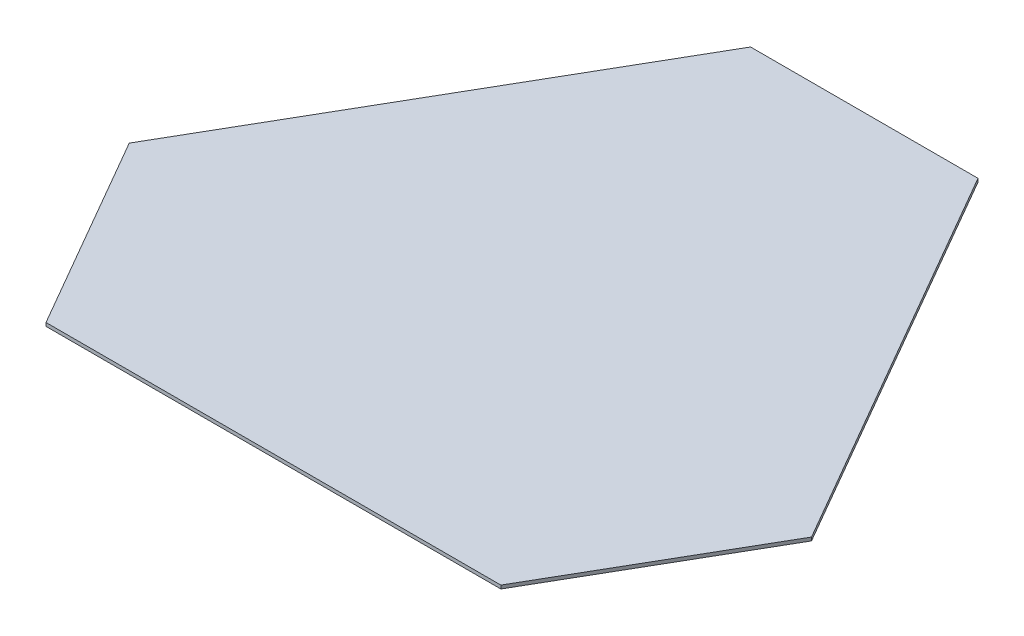
from build123d import *

# Parameters (mm, degrees)
BOSS_EXTRUDE1_DEPTH = 3


with BuildPart() as part:
    # Sketch2 → Boss-Extrude1 (new body)
    with BuildSketch(Plane(origin=(0, 0, 0), x_dir=(1, 0, 0), z_dir=(0, 1, 0))):
        Polygon((100, 288.675134595), (-100, 288.675134595), (-300, -57.735026919), (-250, -144.337567297), (200, 115.470053838), align=None)
        Polygon((300, -57.735026919), (200, 115.470053838), (-250, -144.337567297), (-200, -230.940107676), (200, -230.940107676), align=None)
    extrude(amount=BOSS_EXTRUDE1_DEPTH)


solid = part.part
